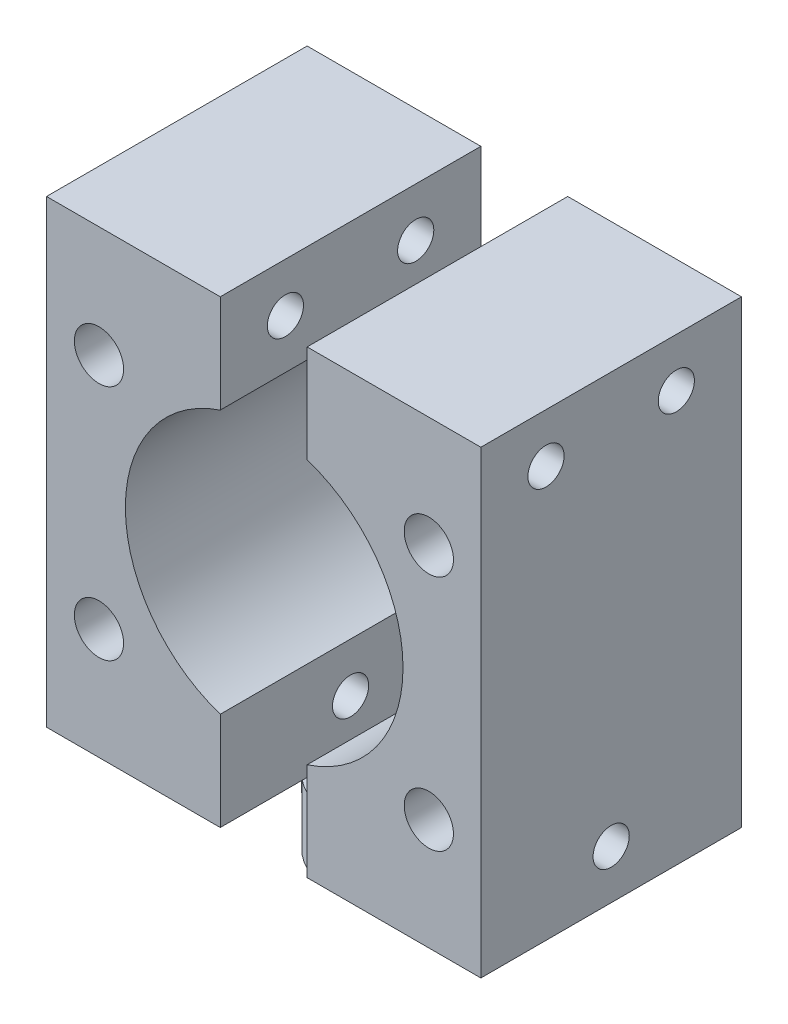
from build123d import *

# Parameters (mm, degrees)
SKETCH2_W             = 12
SKETCH2_H             = 18
EXTRUDE1_DEPTH        = 31.75
EXTRUDE1_2_DEPTH      = 31.75
EXTRUDE2_DEPTH        = 4.5
SKETCH4_R             = 9.5885
EXTRUDE3_DEPTH        = 17
M3_CLEARANCE_HOLE1_D  = 3.4
M3X0_5_TAPPED_HOLE1_D = 2.5


with BuildPart() as part:
    # Sketch2 → Extrude1 (new body)
    with BuildSketch(Plane(origin=(0, 4.5, 0), x_dir=(-1, 0, 0), z_dir=(0, 1, 0))):
        with Locations((9, 0.343878918)):
            Rectangle(SKETCH2_W, SKETCH2_H)
    extrude(amount=EXTRUDE1_DEPTH)



with BuildPart() as body_2:
    # Sketch2 → Extrude1 2 (new body)
    with BuildSketch(Plane(origin=(0, 4.5, 0), x_dir=(-1, 0, 0), z_dir=(0, 1, 0))):
        with Locations((-9, 0.343878918)):
            Rectangle(SKETCH2_W, SKETCH2_H)
    extrude(amount=EXTRUDE1_2_DEPTH)


with BuildPart() as part_1:
    add(part.part)

    add(body_2.part)  # Extrude2 merges body 2
    # Sketch1 → Extrude2 (add)
    with BuildSketch(Plane(origin=(0, 0, 0), x_dir=(1, 0, 0), z_dir=(0, 1, 0))):
        with BuildLine():
            ThreePointArc((4.75, 0), (3.852758752, 2.778263846), (1.5, 4.506939094))
            Line((1.5, 4.506939094), (1.5, -4.506939094))
            ThreePointArc((1.5, -4.506939094), (3.852758752, -2.778263846), (4.75, 0))
        make_face()
        with BuildLine():
            Line((-1.5, -4.506939094), (-1.5, 4.506939094))
            ThreePointArc((-1.5, 4.506939094), (-4.75, 0), (-1.5, -4.506939094))
        make_face()
    extrude(amount=EXTRUDE2_DEPTH)

    # Sketch4 → Extrude3 (cut)
    with BuildSketch(Plane.XY.offset(9.343878918)):
        with Locations((0.033766691, 20.375)):
            Circle(SKETCH4_R)
    extrude(amount=-EXTRUDE3_DEPTH, mode=Mode.SUBTRACT)

    # M3 Clearance Hole1 (through all)
    with Locations(Plane(origin=(-11.377218639, 28.569859147, 9.343878918), x_dir=(1, 0, 0), z_dir=(0, 0, 1))):
        with Locations((0, 0), (0, -16.389718294), (22.782225349, -16.398024537), (22.782225349, 0.008306243)):
            Hole(M3_CLEARANCE_HOLE1_D / 2)

    # M3x0.5 Tapped Hole1 (through all)
    with Locations(Plane(origin=(15, 32.871578641, 4.843878918), x_dir=(0, 0, 1), z_dir=(1, 0, 0))):
        with Locations((0, 0), (-9, 0), (-4.5, 24.993157282)):
            Hole(M3X0_5_TAPPED_HOLE1_D / 2)


solid = part_1.part
